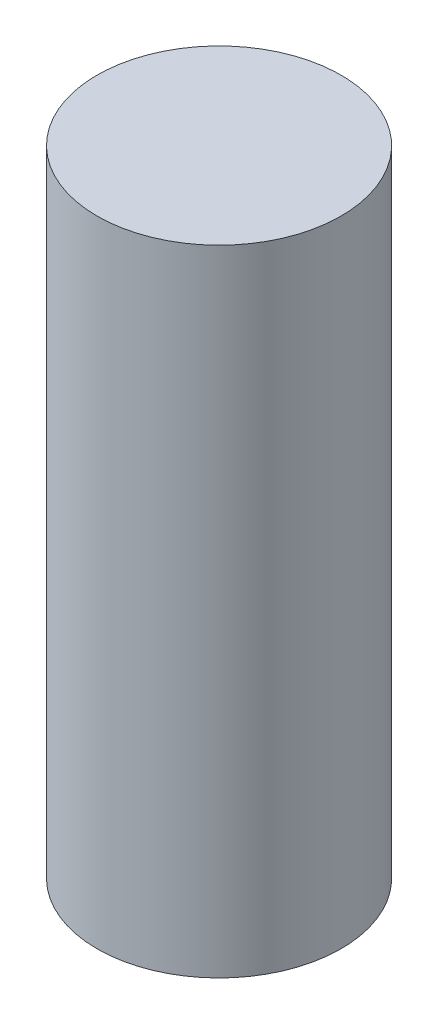
from build123d import *

# Parameters (mm, degrees)
SKETCH1_R           = 0.5
BOSS_EXTRUDE1_DEPTH = 2.6


with BuildPart() as part:
    # Sketch1 → Boss-Extrude1 (new body)
    with BuildSketch(Plane(origin=(0, 0, 0), x_dir=(1, 0, 0), z_dir=(0, 1, 0))):
        Circle(SKETCH1_R)
    extrude(amount=BOSS_EXTRUDE1_DEPTH)


solid = part.part
